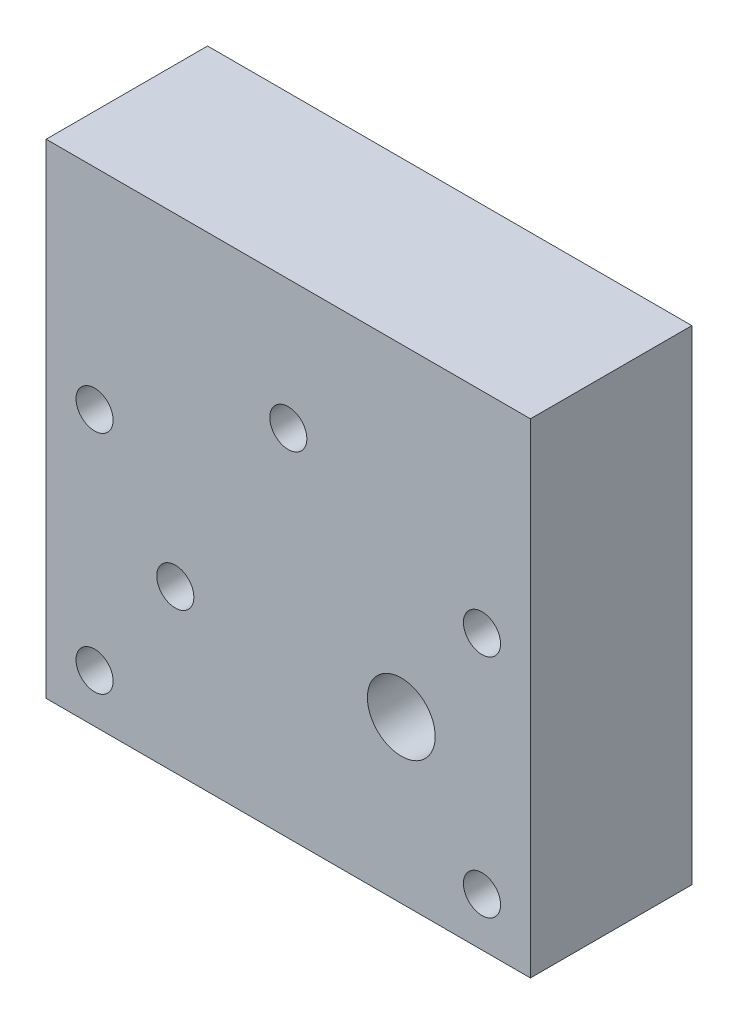
from build123d import *

# Parameters (mm, degrees)
SKETCH1_W           = 30
SKETCH1_H           = 30
SKETCH1_R           = 1.15
SKETCH1_R_2         = 2.1
BOSS_EXTRUDE1_DEPTH = 10


with BuildPart() as part:
    # Sketch1 → Boss-Extrude1 (new body)
    with BuildSketch(Plane.XY):
        with Locations((15, 15)):
            Rectangle(SKETCH1_W, SKETCH1_H)
        with Locations((3, 3)):
            Circle(SKETCH1_R, mode=Mode.SUBTRACT)
        with Locations((3, 17)):
            Circle(SKETCH1_R, mode=Mode.SUBTRACT)
        with Locations((27, 17)):
            Circle(SKETCH1_R, mode=Mode.SUBTRACT)
        with Locations((27, 3)):
            Circle(SKETCH1_R, mode=Mode.SUBTRACT)
        with Locations((8, 10)):
            Circle(SKETCH1_R, mode=Mode.SUBTRACT)
        with Locations((15, 22)):
            Circle(SKETCH1_R, mode=Mode.SUBTRACT)
        with Locations((22, 10)):
            Circle(SKETCH1_R_2, mode=Mode.SUBTRACT)
    extrude(amount=BOSS_EXTRUDE1_DEPTH)


solid = part.part
